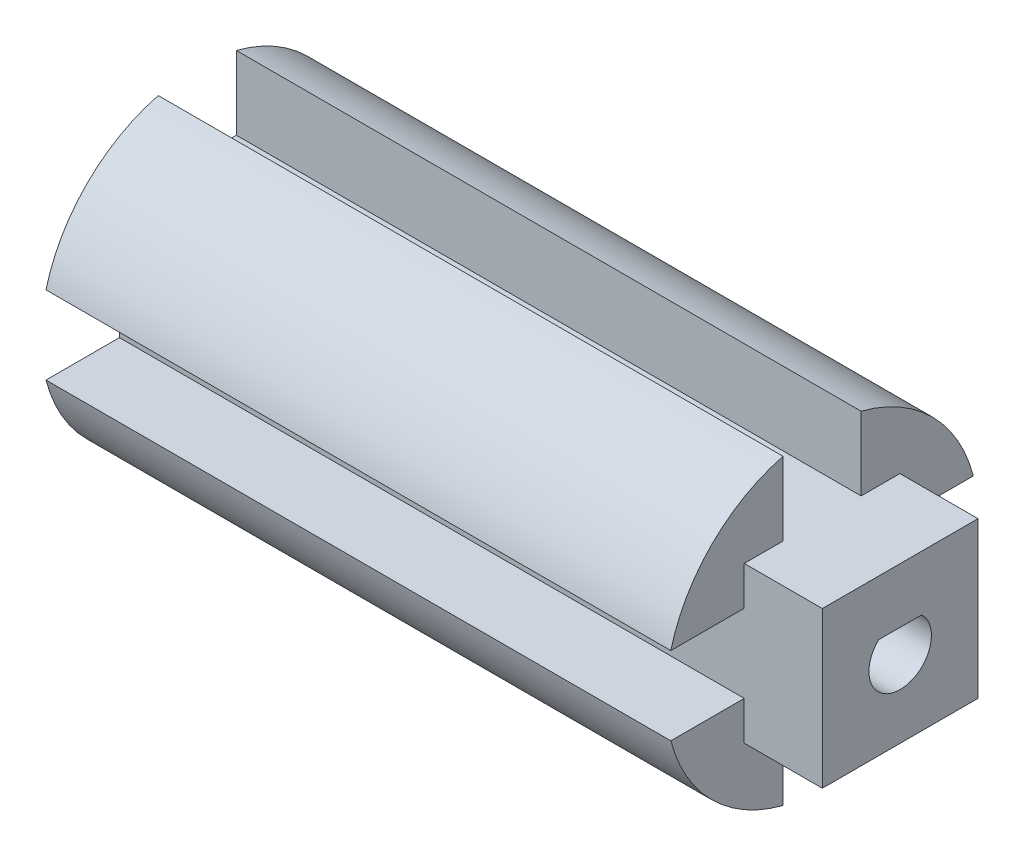
from build123d import *

# Parameters (mm, degrees)
EXTRUDED_CONNECTOR_DEPTH = 90
KEY_CUT_DEPTH            = 18
CUT_EXTRUDE2_DEPTH       = 10


with BuildPart() as part:
    # Sketch1 → Extruded Connector (new body)
    with BuildSketch(Plane(origin=(0, 0, 0), x_dir=(0, 0, -1), z_dir=(1, 0, 0))):
        with BuildLine():
            ThreePointArc((-19.364916731, -5), (-14.142135624, -14.142135624), (-5, -19.364916731))
            Line((-5, -19.364916731), (-5, -9.964916731))
            Line((-5, -9.964916731), (5, -9.964916731))
            Line((5, -9.964916731), (5, -19.364916731))
            ThreePointArc((5, -19.364916731), (14.142135624, -14.142135624), (19.364916731, -5))
            Line((19.364916731, -5), (9.964916731, -5))
            Line((9.964916731, -5), (9.964916731, 5))
            Line((9.964916731, 5), (19.364916731, 5))
            ThreePointArc((19.364916731, 5), (14.142135624, 14.142135624), (5, 19.364916731))
            Line((5, 19.364916731), (5, 9.964916731))
            Line((5, 9.964916731), (-5, 9.964916731))
            Line((-5, 9.964916731), (-5, 19.364916731))
            ThreePointArc((-5, 19.364916731), (-14.142135624, 14.142135624), (-19.364916731, 5))
            Line((-19.364916731, 5), (-9.964916731, 5))
            Line((-9.964916731, 5), (-9.964916731, -5))
            Line((-9.964916731, -5), (-19.364916731, -5))
        make_face()
    extrude(amount=EXTRUDED_CONNECTOR_DEPTH)

    # Sketch10 → Key Cut (cut)
    with BuildSketch(Plane(origin=(90, 0, 0), x_dir=(0, 0, -1), z_dir=(1, 0, 0))):
        with BuildLine():
            Line((-2.754995463, 2.9), (2.754995463, 2.9))
            ThreePointArc((2.754995463, 2.9), (0, -4), (-2.754995463, 2.9))
        make_face()
    extrude(amount=-KEY_CUT_DEPTH, mode=Mode.SUBTRACT)

    # Sketch11 → Cut-Extrude2 (cut)
    with BuildSketch(Plane(origin=(90, 0, 0), x_dir=(0, 0, -1), z_dir=(1, 0, 0))):
        with BuildLine():
            Line((-9.964916731, 9.964916731), (-9.964916731, 5))
            Line((-9.964916731, 5), (-19.364916731, 5))
            ThreePointArc((-19.364916731, 5), (-14.142135624, 14.142135624), (-5, 19.364916731))
            Line((-5, 19.364916731), (-5, 9.964916731))
            Line((-5, 9.964916731), (-9.964916731, 9.964916731))
        make_face()
        with BuildLine():
            Line((9.964916731, 9.964916731), (5, 9.964916731))
            Line((5, 9.964916731), (5, 19.364916731))
            ThreePointArc((5, 19.364916731), (14.142135624, 14.142135624), (19.364916731, 5))
            Line((19.364916731, 5), (9.964916731, 5))
            Line((9.964916731, 5), (9.964916731, 9.964916731))
        make_face()
        with BuildLine():
            Line((9.964916731, -9.964916731), (9.964916731, -5))
            Line((9.964916731, -5), (19.364916731, -5))
            ThreePointArc((19.364916731, -5), (14.142135624, -14.142135624), (5, -19.364916731))
            Line((5, -19.364916731), (5, -9.964916731))
            Line((5, -9.964916731), (9.964916731, -9.964916731))
        make_face()
        with BuildLine():
            Line((-9.964916731, -9.964916731), (-5, -9.964916731))
            Line((-5, -9.964916731), (-5, -19.364916731))
            ThreePointArc((-5, -19.364916731), (-14.142135624, -14.142135624), (-19.364916731, -5))
            Line((-19.364916731, -5), (-9.964916731, -5))
            Line((-9.964916731, -5), (-9.964916731, -9.964916731))
        make_face()
    extrude(amount=-CUT_EXTRUDE2_DEPTH, mode=Mode.SUBTRACT)


solid = part.part
